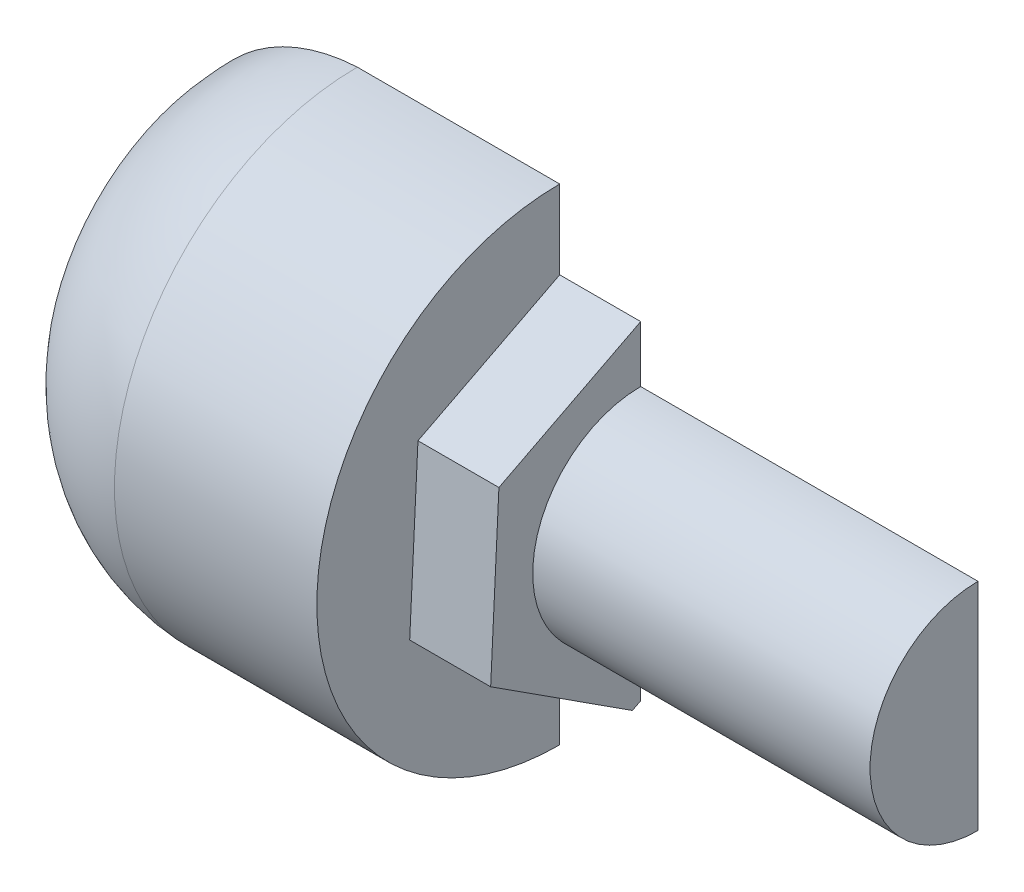
from build123d import *

# Parameters (mm, degrees)
Y_KSEKLIK_EKSTR_ZYON1_DEPTH = 6
IZIM3_R                     = 8
BOSS_EXTRUDE1_DEPTH         = 25
SKETCH3_W                   = 31.552756476
SKETCH3_H                   = 60.481987933
CUT_EXTRUDE2_DEPTH          = 67


with BuildPart() as part:
    # Çizim1 → Döndür1 (revolve)
    with BuildSketch(Plane.XY):
        with BuildLine():
            Line((-25, 13), (-23.9, 11.25))
            Line((-23.9, 11.25), (-21.913347284, 10.75))
            ThreePointArc((-21.913347284, 10.75), (-8.560110762, 12.229864882), (-0.153484939, 1.75))
            Line((-0.153484939, 1.75), (-0.153484939, 0))
            Line((-0.153484939, 0), (0, 0))
            Line((0, 0), (0, 18))
            Line((0, 18), (-15, 18))
            ThreePointArc((-15, 18), (-20.524257416, 16.548514832), (-25, 13))
        make_face()
    revolve(axis=Axis((-0.153484939, 0, 0), (1, 0, 0)))

    # Çizim2 → Yükseklik-Ekstrüzyon1 (add)
    with BuildSketch(Plane(origin=(0, 0, 0), x_dir=(0, 0, -1), z_dir=(1, 0, 0))):
        Polygon((-0.613358655, -12.484575463), (10.505280179, -6.773471909), (11.118638834, 5.711103554), (0.613358655, 12.484575463), (-10.505280179, 6.773471909), (-11.118638834, -5.711103554), align=None)
    extrude(amount=Y_KSEKLIK_EKSTR_ZYON1_DEPTH)

    # Çizim3 → Boss-Extrude1 (add)
    with BuildSketch(Plane(origin=(6, 0, 0), x_dir=(0, 0, -1), z_dir=(1, 0, 0))):
        Circle(IZIM3_R)
    extrude(amount=BOSS_EXTRUDE1_DEPTH)

    # Sketch3 → Cut-Extrude2 (cut)
    with BuildSketch(Plane(origin=(31, 0, 0), x_dir=(0, 0, -1), z_dir=(1, 0, 0))):
        with Locations((15.776378238, -7.418738571)):
            Rectangle(SKETCH3_W, SKETCH3_H)
    extrude(amount=-CUT_EXTRUDE2_DEPTH, mode=Mode.SUBTRACT)


solid = part.part
